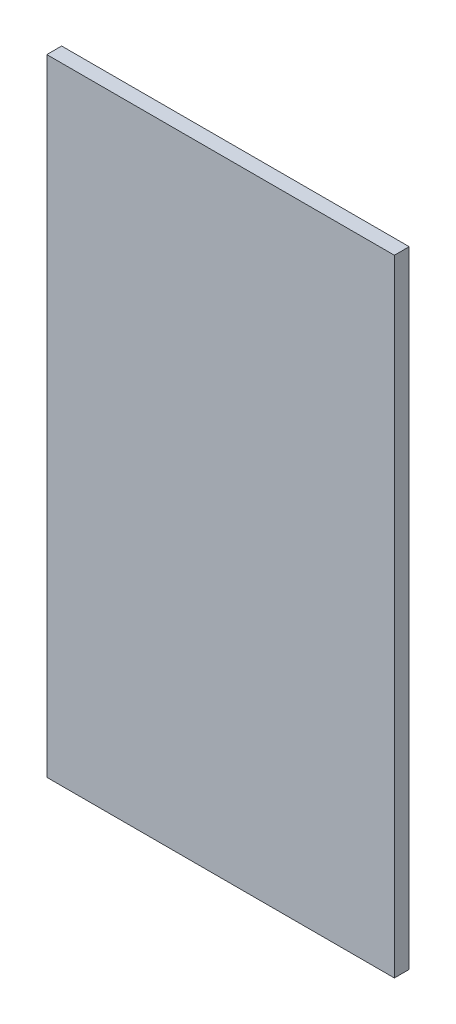
from build123d import *

# Parameters (mm, degrees)
SKETCH1_W           = 211
SKETCH1_H           = 380
BOSS_EXTRUDE1_DEPTH = 9


with BuildPart() as part:
    # Sketch1 → Boss-Extrude1 (new body)
    with BuildSketch(Plane.XY):
        Rectangle(SKETCH1_W, SKETCH1_H)
    extrude(amount=BOSS_EXTRUDE1_DEPTH)


solid = part.part
